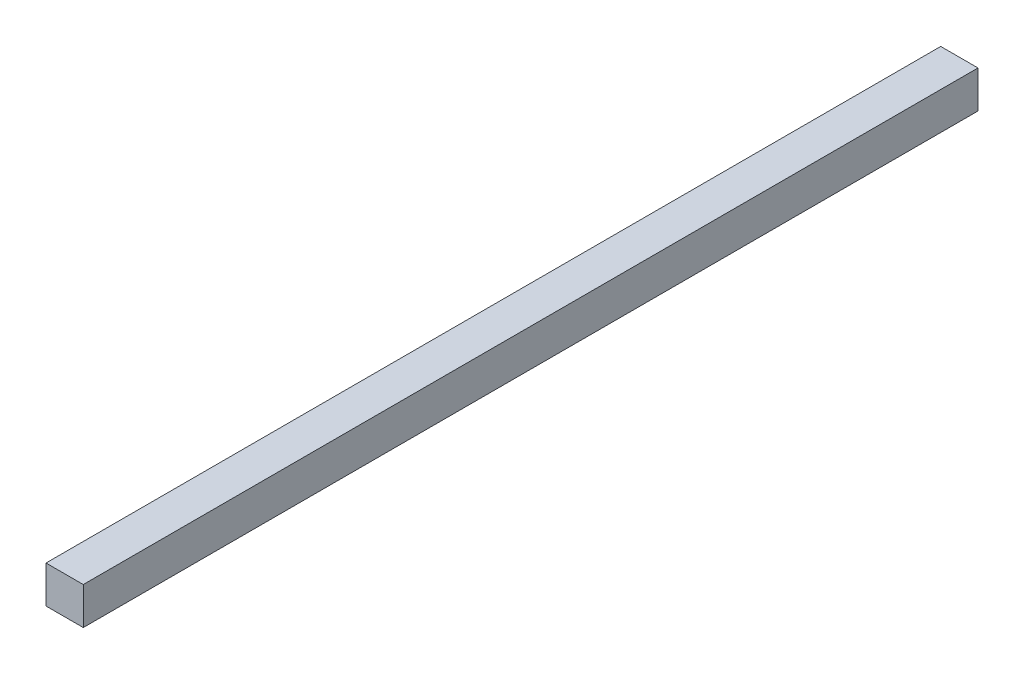
from build123d import *

# Parameters (mm, degrees)
SKETCH1_W           = 25.4
SKETCH1_H           = 609.6
BOSS_EXTRUDE1_DEPTH = 25.4


with BuildPart() as part:
    # Sketch1 → Boss-Extrude1 (new body)
    with BuildSketch(Plane(origin=(0, 0, 0), x_dir=(1, 0, 0), z_dir=(0, 1, 0))):
        with Locations((12.7, 304.8)):
            Rectangle(SKETCH1_W, SKETCH1_H)
    extrude(amount=BOSS_EXTRUDE1_DEPTH)


solid = part.part
